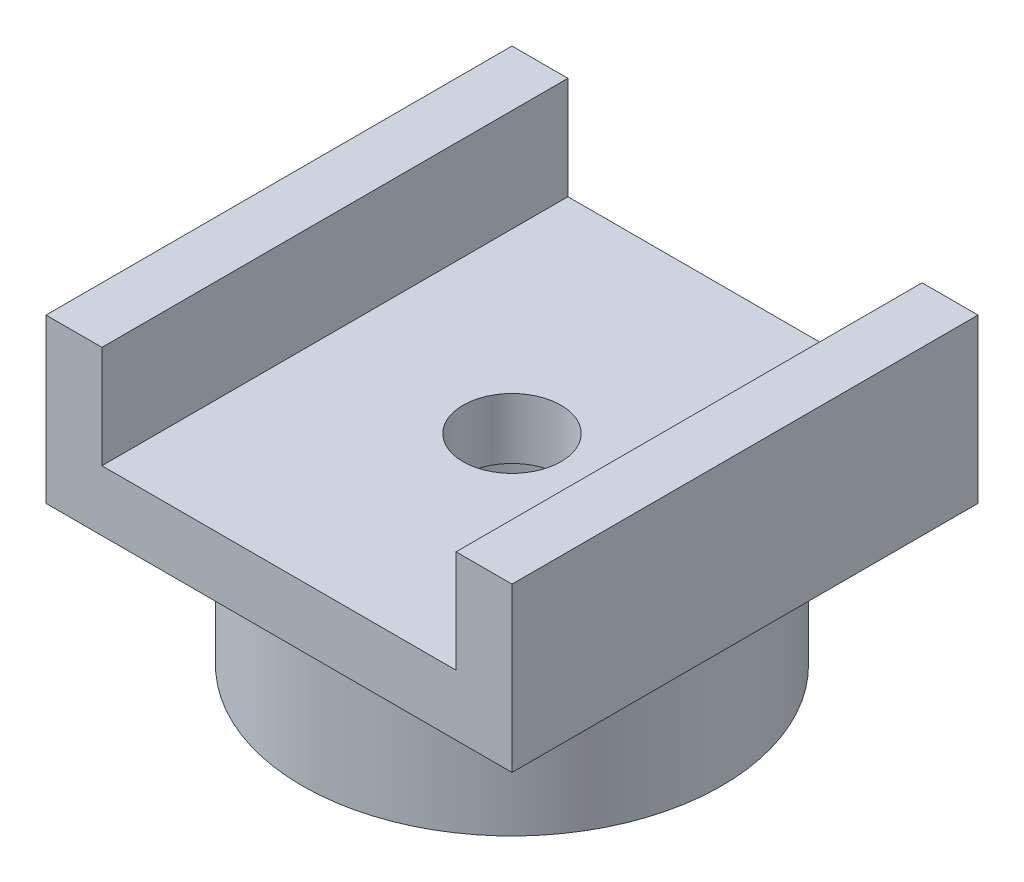
from build123d import *

# Parameters (mm, degrees)
ESBO_O1_R                = 4.5
RESSALTO_EXTRUS_O1_DEPTH = 3
ESBO_O2_R                = 2.8
CORTE_EXTRUS_O1_DEPTH    = 4
ESBO_O3_W                = 10
ESBO_O3_H                = 10
RESSALTO_EXTRUS_O2_DEPTH = 3.5
ESBO_O4_W                = 7.6
ESBO_O4_H                = 10
CORTE_EXTRUS_O2_DEPTH    = 2.2
ESBO_O5_R                = 1.050702539
CORTE_EXTRUS_O3_DEPTH    = 5.3


with BuildPart() as part:
    # Esboço1 → Ressalto-extrusão1 (new body)
    with BuildSketch(Plane(origin=(0, 0, 0), x_dir=(1, 0, 0), z_dir=(0, 1, 0))):
        Circle(ESBO_O1_R)
    extrude(amount=RESSALTO_EXTRUS_O1_DEPTH)

    # Esboço2 → Corte-extrusão1 (cut, through all)
    with BuildSketch(Plane(origin=(0, 3, 0), x_dir=(1, 0, 0), z_dir=(0, 1, 0))):
        Circle(ESBO_O2_R)
    extrude(amount=-CORTE_EXTRUS_O1_DEPTH, mode=Mode.SUBTRACT)

    # Esboço3 → Ressalto-extrusão2 (add)
    with BuildSketch(Plane(origin=(0, 3, 0), x_dir=(1, 0, 0), z_dir=(0, 1, 0))):
        Rectangle(ESBO_O3_W, ESBO_O3_H)
    extrude(amount=RESSALTO_EXTRUS_O2_DEPTH)

    # Esboço4 → Corte-extrusão2 (cut)
    with BuildSketch(Plane(origin=(0, 6.5, 0), x_dir=(1, 0, 0), z_dir=(0, 1, 0))):
        Rectangle(ESBO_O4_W, ESBO_O4_H)
    extrude(amount=-CORTE_EXTRUS_O2_DEPTH, mode=Mode.SUBTRACT)

    # Esboço5 → Corte-extrusão3 (cut, through all)
    with BuildSketch(Plane(origin=(0, 4.3, 0), x_dir=(1, 0, 0), z_dir=(0, 1, 0))):
        Circle(ESBO_O5_R)
    extrude(amount=-CORTE_EXTRUS_O3_DEPTH, mode=Mode.SUBTRACT)


solid = part.part
